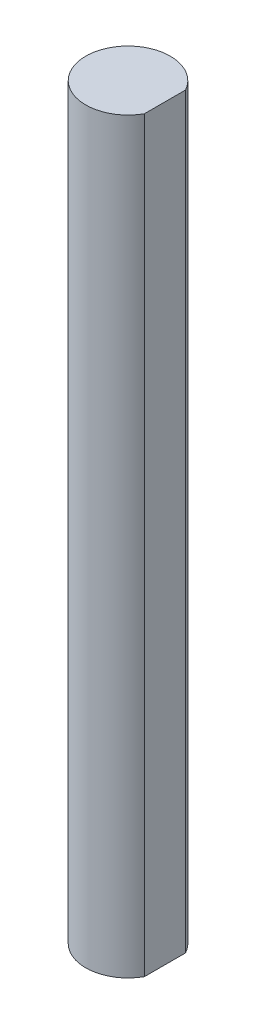
from build123d import *

# Parameters (mm, degrees)
BOSS_EXTRUDE1_DEPTH = 50.8


with BuildPart() as part:
    # Sketch1 → Boss-Extrude1 (new body)
    with BuildSketch(Plane(origin=(0, 0, 0), x_dir=(1, 0, 0), z_dir=(0, 1, 0))):
        with BuildLine():
            Line((2.511643216, 1.39902586), (2.511643216, -1.39902586))
            ThreePointArc((2.511643216, -1.39902586), (-2.875, 0), (2.511643216, 1.39902586))
        make_face()
    extrude(amount=BOSS_EXTRUDE1_DEPTH)


solid = part.part
